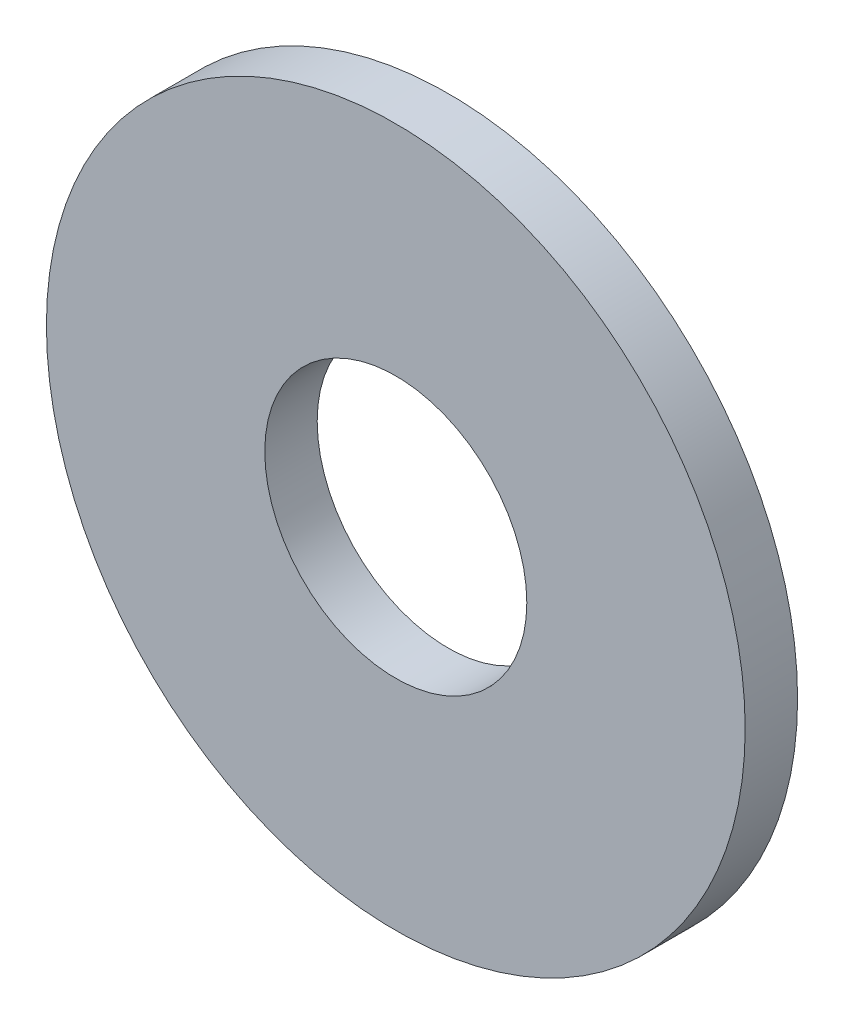
from build123d import *

# Parameters (mm, degrees)
SKETCH1_R           = 4
SKETCH1_R_2         = 1.5
BOSS_EXTRUDE1_DEPTH = 0.6


with BuildPart() as part:
    # Sketch1 → Boss-Extrude1 (new body)
    with BuildSketch(Plane.XY):
        Circle(SKETCH1_R)
        Circle(SKETCH1_R_2, mode=Mode.SUBTRACT)
    extrude(amount=BOSS_EXTRUDE1_DEPTH)


solid = part.part
